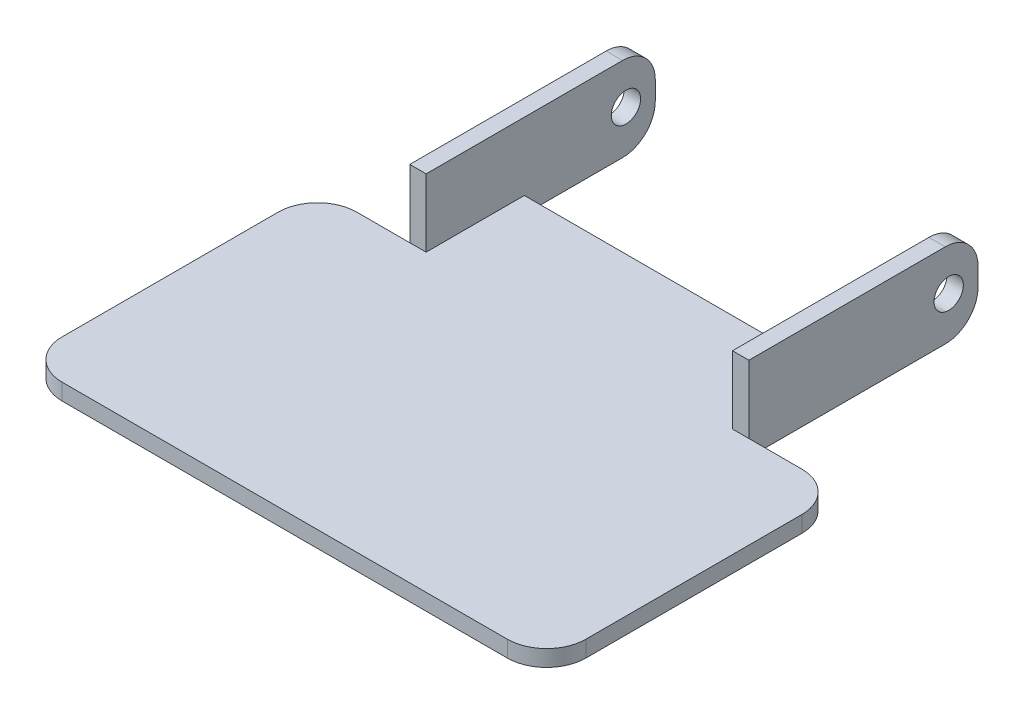
from build123d import *

# Parameters (mm, degrees)
BOSS_EXTRUDE1_DEPTH = 1.5875
SKETCH2_W           = 1.5875
SKETCH2_H           = 22.225
BOSS_EXTRUDE2_DEPTH = 6.5786
FILLET1_R           = 3.175
FILLET2_R           = 3.81
HOLE1_D             = 2.8448


with BuildPart() as part:
    # Sketch1 → Boss-Extrude1 (new body)
    with BuildSketch(Plane(origin=(0, 0, 0), x_dir=(1, 0, 0), z_dir=(0, 1, 0))):
        Polygon((8.9535, 28.575), (8.9535, 50.8), (10.541, 50.8), (10.541, 38.1), (40.259, 38.1), (40.259, 50.8), (41.8465, 50.8), (41.8465, 28.575), (50.8, 28.575), (50.8, 0), (0, 0), (0, 28.575), align=None)
    extrude(amount=BOSS_EXTRUDE1_DEPTH)

    # Sketch2 → Boss-Extrude2 (add)
    with BuildSketch(Plane(origin=(0, 1.5875, 0), x_dir=(1, 0, 0), z_dir=(0, 1, 0))):
        with Locations((9.74725, 39.6875)):
            Rectangle(SKETCH2_W, SKETCH2_H)
        with Locations((41.05275, 39.6875)):
            Rectangle(SKETCH2_W, SKETCH2_H)
    extrude(amount=BOSS_EXTRUDE2_DEPTH)

    # Fillet1
    fillet1_edges = [part.edges().sort_by_distance(p)[0] for p in [
        (9.74725, 0, -50.8),
        (41.05275, 0, -50.8),
        (9.74725, 8.1661, -50.8),
        (41.05275, 8.1661, -50.8),
    ]]
    fillet(fillet1_edges, radius=FILLET1_R)

    # Fillet2
    fillet2_edges = [part.edges().sort_by_distance(p)[0] for p in [
        (0, 0.79375, -28.575),
        (50.8, 0.79375, -28.575),
        (50.8, 0.79375, 0),
        (0, 0.79375, 0),
    ]]
    fillet(fillet2_edges, radius=FILLET2_R)

    # Hole1 (through all)
    with Locations(Plane.ZY.offset(-8.9535)):
        with Locations((-47.9552, 4.08305)):
            Hole(HOLE1_D / 2)


solid = part.part
